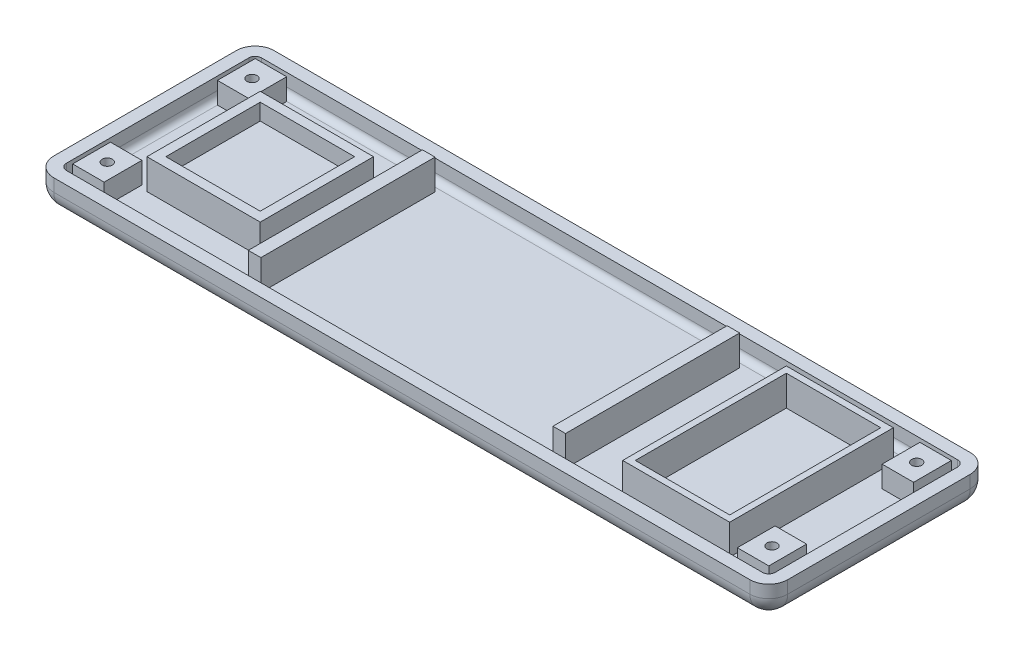
from build123d import *

# Parameters (mm, degrees)
SKETCH1_W                                       = 148.082
SKETCH1_H                                       = 44.45
BOSS_EXTRUDE1_DEPTH                             = 6.35
FILLET1_R                                       = 3.81
SHELL1_T                                        = -2.54
SKETCH3_W                                       = 6.35
SKETCH3_H                                       = 7.62
BOSS_EXTRUDE2_DEPTH                             = 4.318
SKETCH5_W                                       = 22.86
SKETCH5_H                                       = 22.86
BOSS_EXTRUDE3_DEPTH                             = 6.096
SKETCH7_W                                       = 19.05
SKETCH7_H                                       = 19.05
CUT_EXTRUDE1_DEPTH                              = 3.302
SKETCH8_W                                       = 21.59
SKETCH8_H                                       = 33.02
BOSS_EXTRUDE4_DEPTH                             = 6.096
SKETCH9_W                                       = 2.54
SKETCH9_H                                       = 35.135780098
BOSS_EXTRUDE5_DEPTH                             = 6.096
SKETCH12_W                                      = 19.05
SKETCH12_H                                      = 30.48
CUT_EXTRUDE2_DEPTH                              = 6.096
CBORE_FOR_1_PAN_HEAD_MACHINE_SCREW3_D           = 2.0574
CBORE_FOR_1_PAN_HEAD_MACHINE_SCREW3_CBORE_D     = 4.36626
CBORE_FOR_1_PAN_HEAD_MACHINE_SCREW3_CBORE_DEPTH = 1.3462


with BuildPart() as part:
    # Sketch1 → Boss-Extrude1 (new body)
    with BuildSketch(Plane(origin=(0, 0, 0), x_dir=(1, 0, 0), z_dir=(0, 1, 0))):
        Rectangle(SKETCH1_W, SKETCH1_H)
    extrude(amount=BOSS_EXTRUDE1_DEPTH)

    # Fillet1
    fillet1_edges = [part.edges().sort_by_distance(p)[0] for p in [
        (0, 0, -22.225),
        (74.041, 0, 0),
        (0, 0, 22.225),
        (-74.041, 0, 0),
        (-74.041, 3.175, -22.225),
        (74.041, 3.175, -22.225),
        (74.041, 3.175, 22.225),
        (-74.041, 3.175, 22.225),
    ]]
    fillet(fillet1_edges, radius=FILLET1_R)

    # Shell1
    shell1_openings = [part.faces().sort_by_distance(p)[0] for p in [
        (0, 6.35, 0),
    ]]
    offset(amount=SHELL1_T, openings=shell1_openings, kind=Kind.INTERSECTION)

    # Sketch3 → Boss-Extrude2 (add)
    with BuildSketch(Plane(origin=(0, 2.54, 0), x_dir=(1, 0, 0), z_dir=(0, 1, 0))):
        with Locations((-67.056, 14.605)):
            Rectangle(SKETCH3_W, SKETCH3_H)
        with Locations((67.056, 14.605)):
            Rectangle(SKETCH3_W, SKETCH3_H)
        with Locations((-67.056, -14.605)):
            Rectangle(SKETCH3_W, SKETCH3_H)
        with Locations((67.056, -14.605)):
            Rectangle(SKETCH3_W, SKETCH3_H)
    extrude(amount=BOSS_EXTRUDE2_DEPTH)

    # Sketch5 → Boss-Extrude3 (add)
    with BuildSketch(Plane(origin=(0, 2.54, 0), x_dir=(1, 0, 0), z_dir=(0, 1, 0))):
        with Locations((-50.8, 0)):
            Rectangle(SKETCH5_W, SKETCH5_H)
    extrude(amount=BOSS_EXTRUDE3_DEPTH)

    # Sketch7 → Cut-Extrude1 (cut)
    with BuildSketch(Plane(origin=(0, 8.636, 0), x_dir=(1, 0, 0), z_dir=(0, 1, 0))):
        with Locations((-50.8, 0)):
            Rectangle(SKETCH7_W, SKETCH7_H)
    extrude(amount=-CUT_EXTRUDE1_DEPTH, mode=Mode.SUBTRACT)

    # Sketch8 → Boss-Extrude4 (add)
    with BuildSketch(Plane(origin=(0, 2.54, 0), x_dir=(1, 0, 0), z_dir=(0, 1, 0))):
        with Locations((49.639483249, 0)):
            Rectangle(SKETCH8_W, SKETCH8_H)
    extrude(amount=BOSS_EXTRUDE4_DEPTH)

    # Sketch9 → Boss-Extrude5 (add)
    with BuildSketch(Plane(origin=(0, 2.54, 0), x_dir=(1, 0, 0), z_dir=(0, 1, 0))):
        with Locations((-34.367719814, 0)):
            Rectangle(SKETCH9_W, SKETCH9_H)
        with Locations((27.100280186, 0)):
            Rectangle(SKETCH9_W, SKETCH9_H)
    extrude(amount=BOSS_EXTRUDE5_DEPTH)

    # Sketch12 → Cut-Extrude2 (cut)
    with BuildSketch(Plane(origin=(0, 8.636, 0), x_dir=(1, 0, 0), z_dir=(0, 1, 0))):
        with Locations((49.639483249, 0)):
            Rectangle(SKETCH12_W, SKETCH12_H)
    extrude(amount=-CUT_EXTRUDE2_DEPTH, mode=Mode.SUBTRACT)

    # CBORE for _1 Pan Head Machine Screw3 (through all)
    with Locations(Plane(origin=(0, 0, 0), x_dir=(-1, 0, 0), z_dir=(0, -1, 0))):
        with Locations((-67.056, 14.605), (-67.056, -14.605), (67.056, -14.605), (67.056, 14.605)):
            CounterBoreHole(CBORE_FOR_1_PAN_HEAD_MACHINE_SCREW3_D / 2, CBORE_FOR_1_PAN_HEAD_MACHINE_SCREW3_CBORE_D / 2, CBORE_FOR_1_PAN_HEAD_MACHINE_SCREW3_CBORE_DEPTH)


solid = part.part
